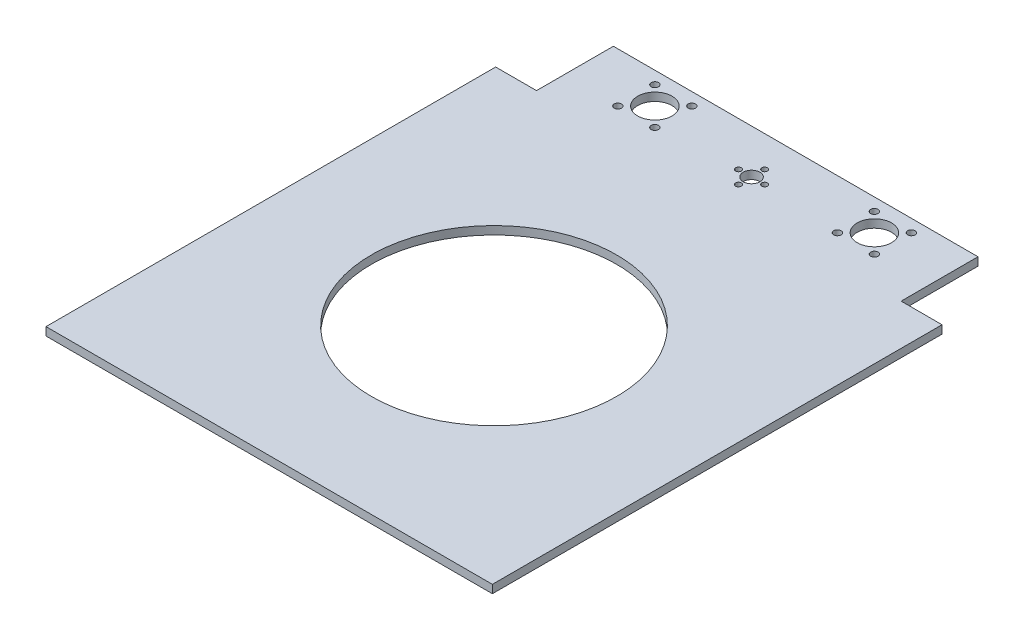
from build123d import *

# Parameters (mm, degrees)
SKETCH1_W           = 273
SKETCH1_H           = 275
SKETCH1_R           = 75
SKETCH1_W_2         = 223
SKETCH1_H_2         = 47
BOSS_EXTRUDE1_DEPTH = 5
SKETCH2_R           = 5.1
SKETCH2_R_2         = 1.75
SKETCH2_R_3         = 10.5
SKETCH2_R_4         = 2.25
CUT_EXTRUDE1_DEPTH  = 10


with BuildPart() as part:
    # Sketch1 → Boss-Extrude1 (new body)
    with BuildSketch(Plane(origin=(0, 0, 0), x_dir=(1, 0, 0), z_dir=(0, 1, 0))):
        with Locations((136.5, 137.5)):
            Rectangle(SKETCH1_W, SKETCH1_H)
        with Locations((136.5, 137.5)):
            Circle(SKETCH1_R, mode=Mode.SUBTRACT)
        with Locations((136.5, 298.5)):
            Rectangle(SKETCH1_W_2, SKETCH1_H_2)
    extrude(amount=BOSS_EXTRUDE1_DEPTH)

    # Sketch2 → Cut-Extrude1 (cut)
    with BuildSketch(Plane(origin=(0, 5, 0), x_dir=(1, 0, 0), z_dir=(0, 1, 0))):
        with Locations((136.5, 295)):
            Circle(SKETCH2_R)
        with Locations((136.5, 303)):
            Circle(SKETCH2_R_2)
        with Locations((136.5, 287)):
            Circle(SKETCH2_R_2)
        with Locations((128.5, 295)):
            Circle(SKETCH2_R_2)
        with Locations((144.5, 295)):
            Circle(SKETCH2_R_2)
        with Locations((69.38, 303)):
            Circle(SKETCH2_R_3)
        with Locations((80.693708499, 314.313708499)):
            Circle(SKETCH2_R_4)
        with Locations((58.066291501, 314.313708499)):
            Circle(SKETCH2_R_4)
        with Locations((80.693708499, 291.686291501)):
            Circle(SKETCH2_R_4)
        with Locations((58.066291501, 291.686291501)):
            Circle(SKETCH2_R_4)
        with Locations((203.62, 303)):
            Circle(SKETCH2_R_3)
        with Locations((214.933708499, 291.686291501)):
            Circle(SKETCH2_R_4)
        with Locations((192.306291501, 291.686291501)):
            Circle(SKETCH2_R_4)
        with Locations((192.306291501, 314.313708499)):
            Circle(SKETCH2_R_4)
        with Locations((214.933708499, 314.313708499)):
            Circle(SKETCH2_R_4)
    extrude(amount=-CUT_EXTRUDE1_DEPTH, mode=Mode.SUBTRACT)


solid = part.part
